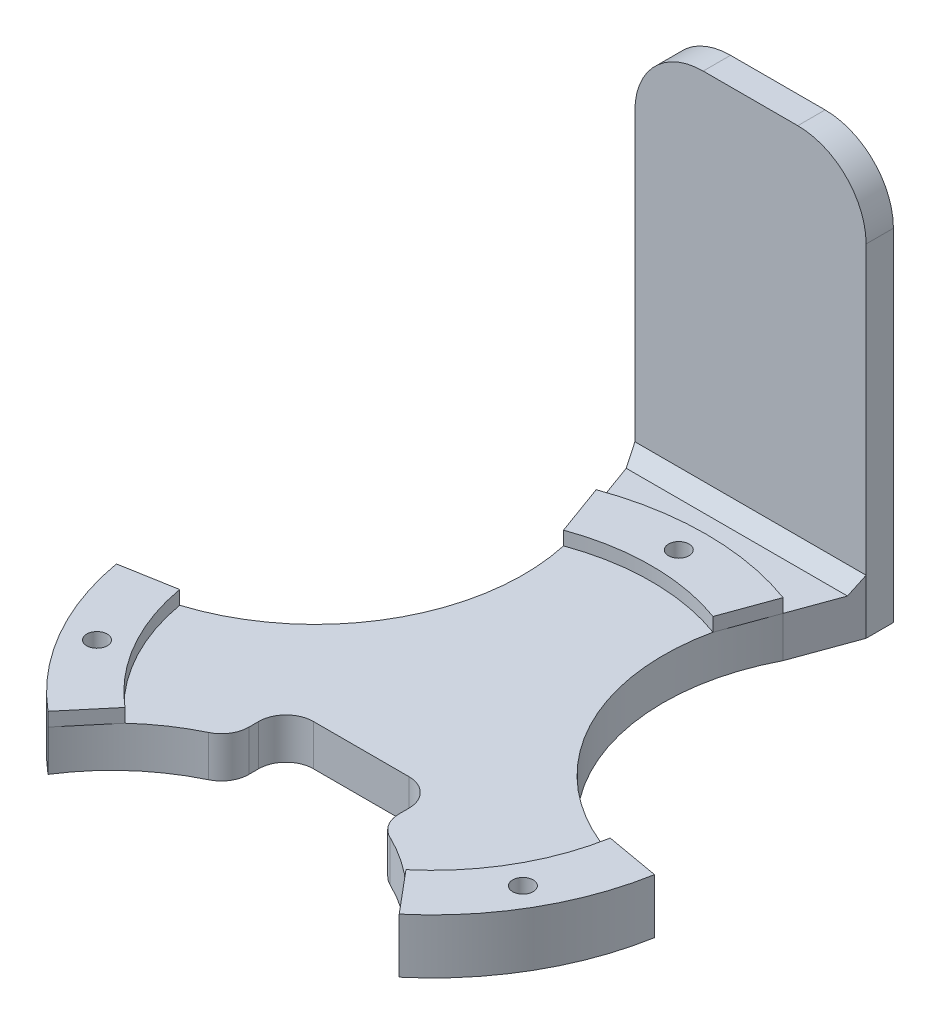
from build123d import *

# Parameters (mm, degrees)
SKETCH1_R           = 40
BOSS_EXTRUDE1_DEPTH = 6
SKETCH2_R           = 1.5
BOSS_EXTRUDE2_DEPTH = 2
SKETCH16_R          = 1.5
CUT_EXTRUDE9_DEPTH  = 9
CIRPATTERN1_COUNT   = 3
SKETCH5_R           = 30.471270003
CUT_EXTRUDE3_DEPTH  = 7
CIRPATTERN2_COUNT   = 3
BOSS_EXTRUDE3_DEPTH = 6
SKETCH18_W          = 33.849231786
SKETCH18_H          = 60
BOSS_EXTRUDE4_DEPTH = 4
CHAMFER1_SIZE       = 2
SKETCH19_W          = 22
SKETCH19_H          = 10
CUT_EXTRUDE10_DEPTH = 25
FILLET1_R           = 4
FILLET2_R           = 10


with BuildPart() as part:
    # Sketch1 → Boss-Extrude1 (new body)
    with BuildSketch(Plane(origin=(0, 0, 0), x_dir=(1, 0, 0), z_dir=(0, 1, 0))):
        Circle(SKETCH1_R)
    extrude(amount=BOSS_EXTRUDE1_DEPTH)

    # Sketch2 → Boss-Extrude2 (add)
    with BuildSketch(Plane(origin=(0, 6, 0), x_dir=(1, 0, 0), z_dir=(0, 1, 0))):
        with BuildLine():
            Line((-13.680805733, 37.587704831), (-10.944644586, 30.070163865))
            ThreePointArc((-10.944644586, 30.070163865), (0, 32), (10.944644586, 30.070163865))
            Line((10.944644586, 30.070163865), (13.680805733, 37.587704831))
            ThreePointArc((13.680805733, 37.587704831), (0, 40), (-13.680805733, 37.587704831))
        make_face()
        with Locations((0, 36)):
            Circle(SKETCH2_R, mode=Mode.SUBTRACT)
    boss_extrude2 = extrude(amount=BOSS_EXTRUDE2_DEPTH)

    # Sketch16 → Cut-Extrude9 (cut, through all)
    with BuildSketch(Plane(origin=(0, 8, 0), x_dir=(1, 0, 0), z_dir=(0, 1, 0))):
        with Locations((0, 36)):
            Circle(SKETCH16_R)
    cut_extrude9 = extrude(amount=-CUT_EXTRUDE9_DEPTH, mode=Mode.SUBTRACT)

    # CirPattern1: Boss-Extrude2, Cut-Extrude9 ×3 about axis
    cirpattern1_axis = Axis((0, 0, 0), (0, 1, 0))
    for i in range(1, CIRPATTERN1_COUNT):
        add(boss_extrude2.rotate(cirpattern1_axis, i * 360 / CIRPATTERN1_COUNT))
        add(cut_extrude9.rotate(cirpattern1_axis, i * 360 / CIRPATTERN1_COUNT), mode=Mode.SUBTRACT)

    # Sketch5 → Cut-Extrude3 (cut, through all)
    with BuildSketch(Plane(origin=(0, 6, 0), x_dir=(1, 0, 0), z_dir=(0, 1, 0))):
        with Locations((40.698571494, 23.497331208)):
            Circle(SKETCH5_R)
    cut_extrude3 = extrude(amount=-CUT_EXTRUDE3_DEPTH, mode=Mode.SUBTRACT)

    # CirPattern2: Cut-Extrude3 ×3 about axis
    cirpattern2_axis = Axis((0, 0, 0), (0, 1, 0))
    for i in range(1, CIRPATTERN2_COUNT):
        add(cut_extrude3.rotate(cirpattern2_axis, i * 360 / CIRPATTERN2_COUNT), mode=Mode.SUBTRACT)

    # Sketch17 → Boss-Extrude3 (add)
    with BuildSketch(Plane(origin=(0, 0, 0), x_dir=(1, 0, 0), z_dir=(0, 1, 0))):
        with BuildLine():
            Line((-13.680805733, 37.587704831), (-16.924615893, 46.5))
            Line((-16.924615893, 46.5), (16.924615893, 46.5))
            Line((16.924615893, 46.5), (13.680805733, 37.587704831))
            ThreePointArc((13.680805733, 37.587704831), (0, 40), (-13.680805733, 37.587704831))
        make_face()
    extrude(amount=BOSS_EXTRUDE3_DEPTH)

    # Sketch18 → Boss-Extrude4 (add)
    with BuildSketch(Plane(origin=(0, 0, -46.5), x_dir=(-1, 0, 0), z_dir=(0, 0, -1))):
        with Locations((0, 30)):
            Rectangle(SKETCH18_W, SKETCH18_H)
    extrude(amount=BOSS_EXTRUDE4_DEPTH)

    # Chamfer1
    chamfer1_edges = [part.edges().sort_by_distance(p)[0] for p in [
        (0, 6, -46.5),
    ]]
    chamfer(chamfer1_edges, length=CHAMFER1_SIZE)

    # Sketch19 → Cut-Extrude10 (cut)
    with BuildSketch(Plane(origin=(0, 6, 0), x_dir=(1, 0, 0), z_dir=(0, 1, 0))):
        with Locations((0, -15.5)):
            Rectangle(SKETCH19_W, SKETCH19_H)
    extrude(amount=-CUT_EXTRUDE10_DEPTH, mode=Mode.SUBTRACT)

    # Fillet1
    fillet1_edges = [part.edges().sort_by_distance(p)[0] for p in [
        (-11, 3, 18.578147929),
        (11, 3, 18.578147929),
        (-11, 3, 10.5),
        (11, 3, 10.5),
    ]]
    fillet(fillet1_edges, radius=FILLET1_R)

    # Fillet2
    fillet2_edges = [part.edges().sort_by_distance(p)[0] for p in [
        (16.924615893, 60, -48.5),
        (-16.924615893, 60, -48.5),
    ]]
    fillet(fillet2_edges, radius=FILLET2_R)


solid = part.part
